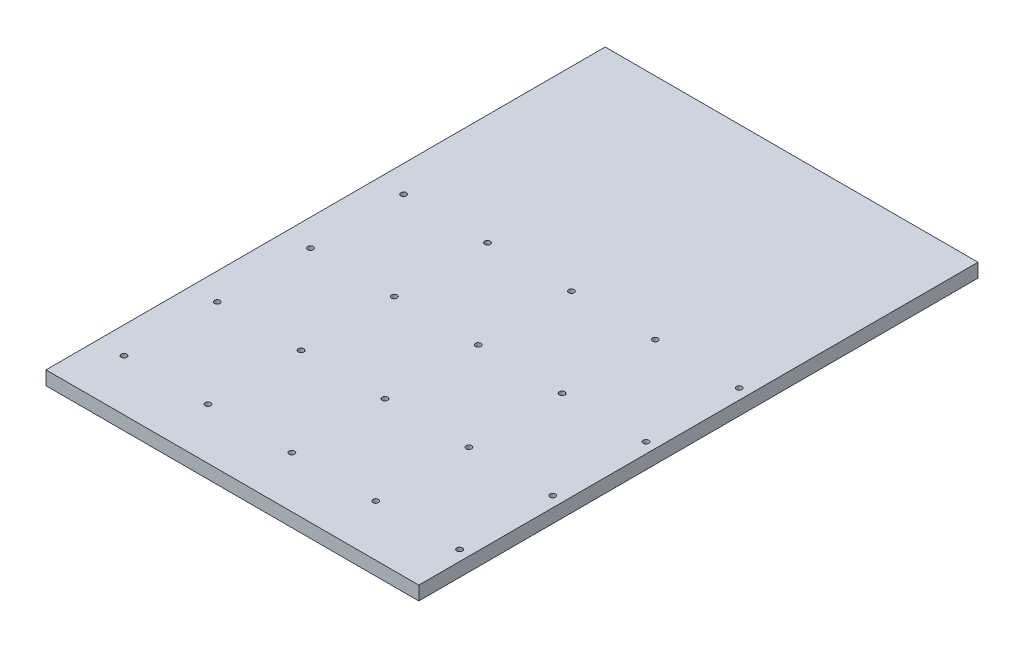
from build123d import *

# Parameters (mm, degrees)
SKETCH1_W           = 400
SKETCH1_H           = 600
SKETCH1_R           = 3
BOSS_EXTRUDE1_DEPTH = 14.8


with BuildPart() as part:
    # Sketch1 → Boss-Extrude1 (new body)
    with BuildSketch(Plane(origin=(0, 0, 0), x_dir=(1, 0, 0), z_dir=(0, 1, 0))):
        with Locations((200, 300)):
            Rectangle(SKETCH1_W, SKETCH1_H)
        with Locations((28.75, 355)):
            Circle(SKETCH1_R, mode=Mode.SUBTRACT)
        with Locations((118.75, 355)):
            Circle(SKETCH1_R, mode=Mode.SUBTRACT)
        with Locations((208.75, 355)):
            Circle(SKETCH1_R, mode=Mode.SUBTRACT)
        with Locations((298.75, 355)):
            Circle(SKETCH1_R, mode=Mode.SUBTRACT)
        with Locations((388.75, 355)):
            Circle(SKETCH1_R, mode=Mode.SUBTRACT)
        with Locations((28.75, 255)):
            Circle(SKETCH1_R, mode=Mode.SUBTRACT)
        with Locations((118.75, 255)):
            Circle(SKETCH1_R, mode=Mode.SUBTRACT)
        with Locations((208.75, 255)):
            Circle(SKETCH1_R, mode=Mode.SUBTRACT)
        with Locations((298.75, 255)):
            Circle(SKETCH1_R, mode=Mode.SUBTRACT)
        with Locations((388.75, 255)):
            Circle(SKETCH1_R, mode=Mode.SUBTRACT)
        with Locations((28.75, 155)):
            Circle(SKETCH1_R, mode=Mode.SUBTRACT)
        with Locations((118.75, 155)):
            Circle(SKETCH1_R, mode=Mode.SUBTRACT)
        with Locations((208.75, 155)):
            Circle(SKETCH1_R, mode=Mode.SUBTRACT)
        with Locations((298.75, 155)):
            Circle(SKETCH1_R, mode=Mode.SUBTRACT)
        with Locations((388.75, 155)):
            Circle(SKETCH1_R, mode=Mode.SUBTRACT)
        with Locations((28.75, 55)):
            Circle(SKETCH1_R, mode=Mode.SUBTRACT)
        with Locations((118.75, 55)):
            Circle(SKETCH1_R, mode=Mode.SUBTRACT)
        with Locations((208.75, 55)):
            Circle(SKETCH1_R, mode=Mode.SUBTRACT)
        with Locations((298.75, 55)):
            Circle(SKETCH1_R, mode=Mode.SUBTRACT)
        with Locations((388.75, 55)):
            Circle(SKETCH1_R, mode=Mode.SUBTRACT)
    extrude(amount=BOSS_EXTRUDE1_DEPTH)


solid = part.part
